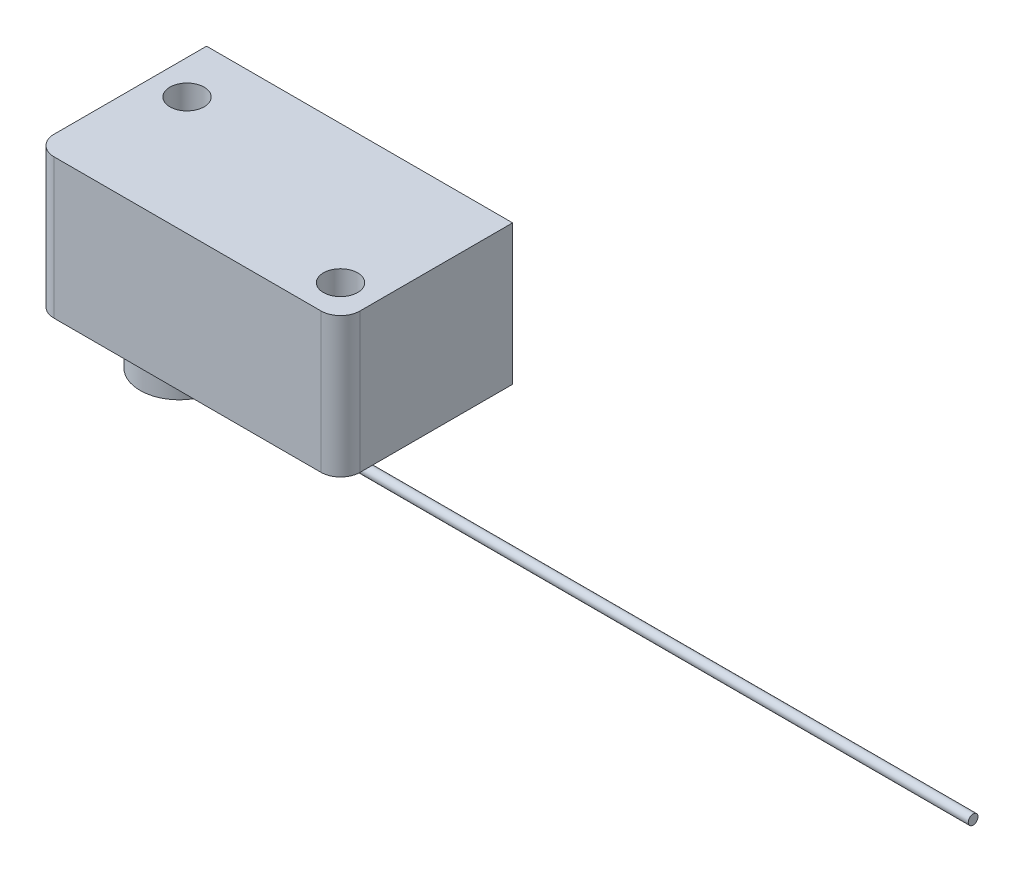
from build123d import *

# Parameters (mm, degrees)
EXTRUDE_1_DEPTH     = 14.3
SKETCH_2_R          = 1.75
CUT_EXTRUDE_1_DEPTH = 15.3
SKETCH_3_R          = 4
EXTRUDE_2_DEPTH     = 4
EXTRUDE_START       = -10
SKETCH_4_R          = 0.5
EXTRUDE_3_DEPTH     = 80


with BuildPart() as part:
    # 草圖1 → 填料-伸長1 (new body)
    with BuildSketch(Plane(origin=(0, 0, 0), x_dir=(1, 0, 0), z_dir=(0, 1, 0))):
        with BuildLine():
            Line((2, 0), (29.3, 0))
            ThreePointArc((29.3, 0), (30.714213562, 0.585786438), (31.3, 2))
            Line((31.3, 2), (31.3, 17.6))
            Line((31.3, 17.6), (0, 17.6))
            Line((0, 17.6), (0, 2))
            ThreePointArc((0, 2), (0.585786438, 0.585786438), (2, 0))
        make_face()
    extrude(amount=EXTRUDE_1_DEPTH)

    # 草圖2 → 除料-伸長1 (cut, through all)
    with BuildSketch(Plane(origin=(0, 14.3, 0), x_dir=(1, 0, 0), z_dir=(0, 1, 0))):
        with Locations((27.8, 3.5)):
            Circle(SKETCH_2_R)
        with Locations((3.5, 12.1)):
            Circle(SKETCH_2_R)
    extrude(amount=-CUT_EXTRUDE_1_DEPTH, mode=Mode.SUBTRACT)

    # 草圖3 → 填料-伸長2 (add)
    with BuildSketch(Plane.XZ):
        with Locations((8.8, -6)):
            Circle(SKETCH_3_R)
    extrude(amount=EXTRUDE_2_DEPTH)

    # 草圖4 → 填料-伸長3 (add)
    with BuildSketch(Plane.ZY.offset(EXTRUDE_START)):
        with Locations((-6, -3.4)):
            Circle(SKETCH_4_R)
    extrude(amount=-EXTRUDE_3_DEPTH)


solid = part.part
